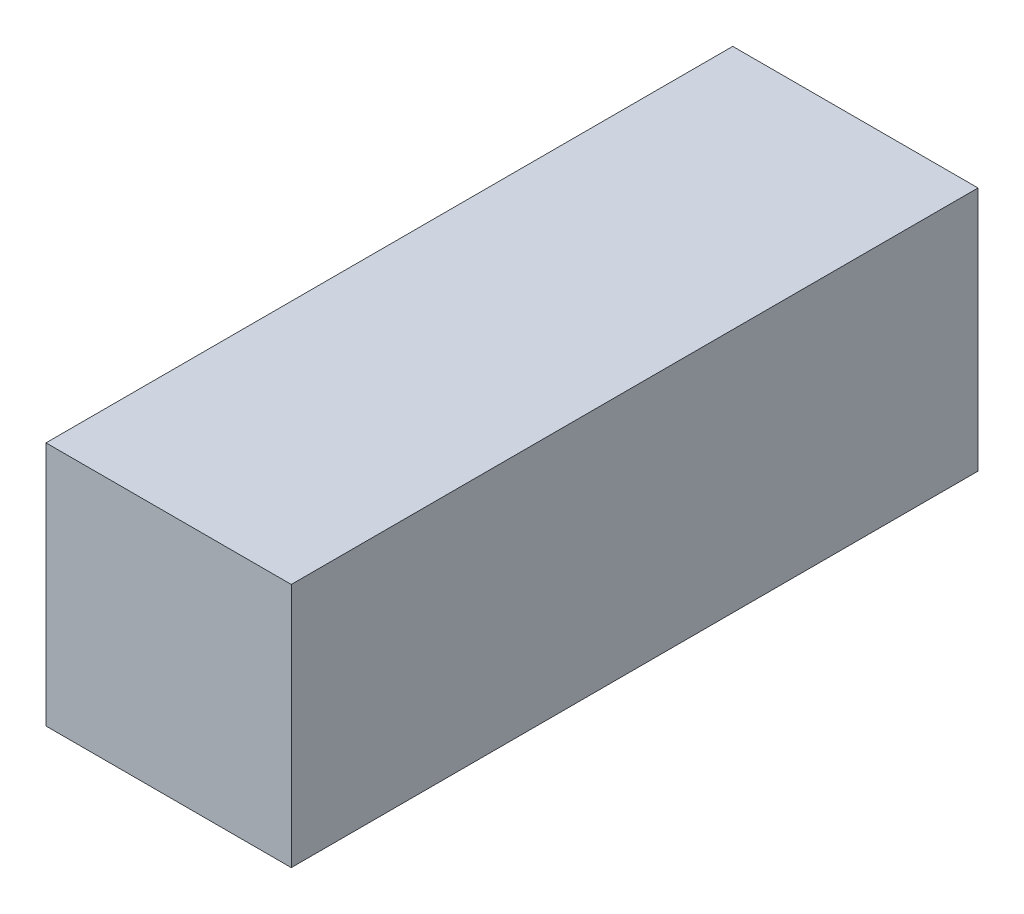
from build123d import *

# Parameters (mm, degrees)
SKETCH1_W           = 50
SKETCH1_H           = 50
BOSS_EXTRUDE1_DEPTH = 140


with BuildPart() as part:
    # Sketch1 → Boss-Extrude1 (new body)
    with BuildSketch(Plane.XY):
        with Locations((-25, 25)):
            Rectangle(SKETCH1_W, SKETCH1_H)
    extrude(amount=BOSS_EXTRUDE1_DEPTH)


solid = part.part
